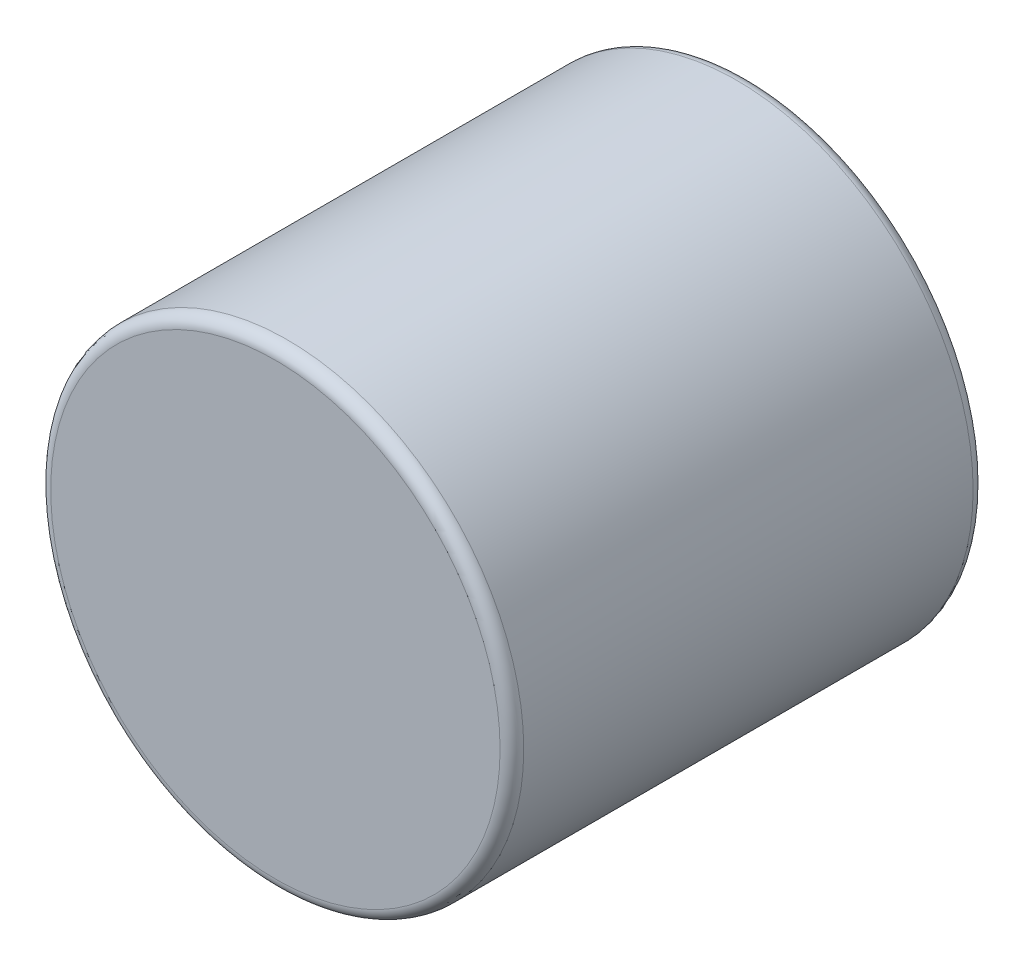
from build123d import *

# Parameters (mm, degrees)
SKETCH3_R                = 1.5875
BOSS_EXTRUDE1_DEPTH      = 1.5875
BOSS_EXTRUDE1_DEPTH_BACK = 1.5875
FILLET1_R                = 0.079375


with BuildPart() as part:
    # Sketch3 → Boss-Extrude1 (new body, two sides)
    with BuildSketch(Plane.XY) as boss_extrude1_sk:
        Circle(SKETCH3_R)
    extrude(amount=BOSS_EXTRUDE1_DEPTH)
    extrude(boss_extrude1_sk.sketch, amount=-BOSS_EXTRUDE1_DEPTH_BACK)

    # Fillet1
    fillet1_edges = [part.edges().sort_by_distance(p)[0] for p in [
        (-1.5875, 0, -1.5875),
        (-1.5875, 0, 1.5875),
    ]]
    fillet(fillet1_edges, radius=FILLET1_R)


solid = part.part
